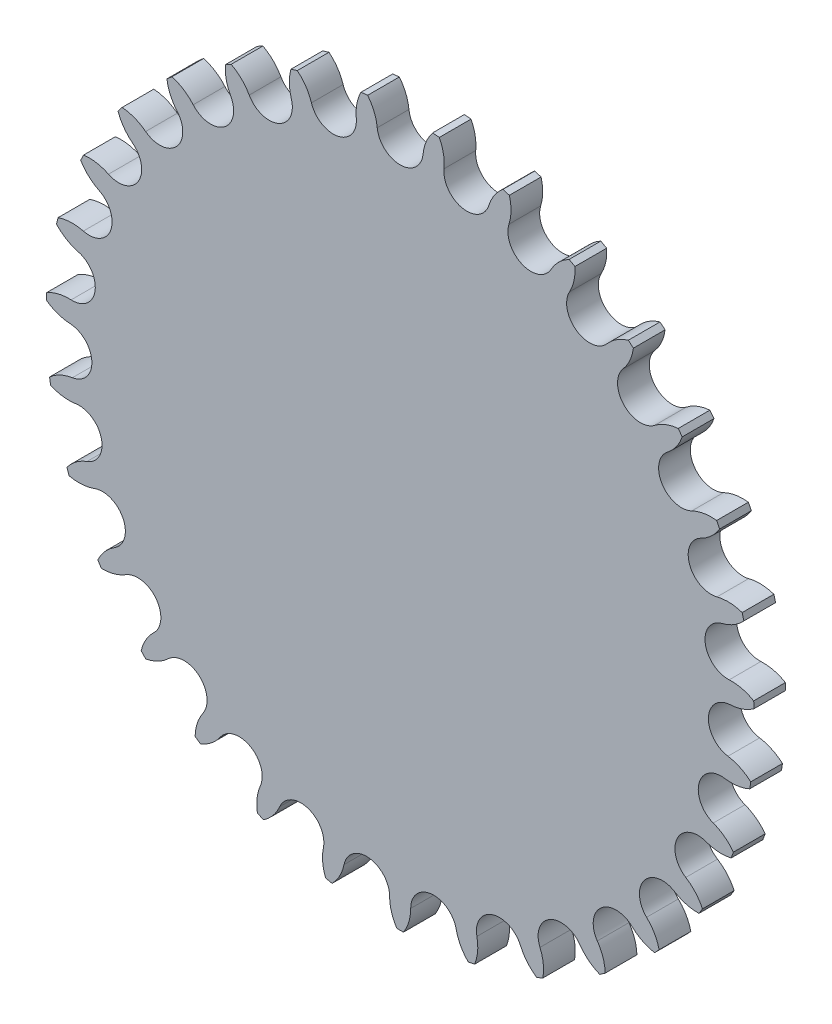
from build123d import *

# Parameters (mm, degrees)
EXTRUDE_1_DEPTH          = 6
PATTERN_CIRCULAR_1_COUNT = 31


with BuildPart() as part:
    # Эскиз2 → Бобышка-Вытянуть1 (new body)
    with BuildSketch(Plane.XY):
        with BuildLine():
            Line((0, 0), (0, 58.411683041))
            ThreePointArc((0, 58.411683041), (2.919525995, 59.535213877), (4.332655903, 62.326094999))
            ThreePointArc((4.332655903, 62.326094999), (4.920924349, 64.665322075), (6.153657531, 66.738583268))
            ThreePointArc((6.153657531, 66.738583268), (6.78047121, 66.67781646), (7.406686245, 66.611162702))
            ThreePointArc((7.406686245, 66.611162702), (8.196840897, 64.332193922), (8.302184504, 61.922433394))
            ThreePointArc((8.302184504, 61.922433394), (9.12458732, 58.904220813), (11.758185352, 57.215992458))
            Line((11.758185352, 57.215992458), (0, 0))
        make_face()
    extrude_1 = extrude(amount=EXTRUDE_1_DEPTH)

    # Круговой массив1: Бобышка-Вытянуть1 ×31 about axis
    pattern_circular_1_axis = Axis((0, 0, 0), (0, 0, 1))
    for i in range(1, PATTERN_CIRCULAR_1_COUNT):
        add(extrude_1.rotate(pattern_circular_1_axis, i * 360 / PATTERN_CIRCULAR_1_COUNT))


solid = part.part
